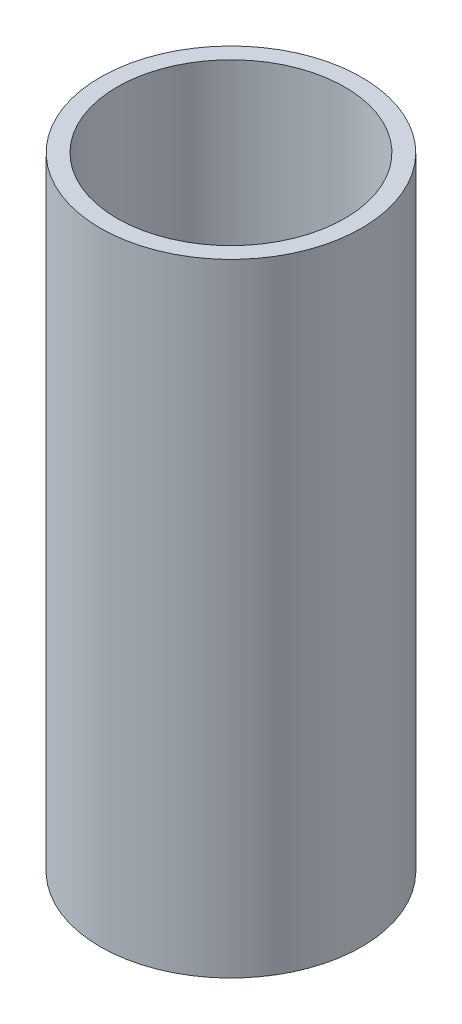
from build123d import *

# Parameters (mm, degrees)
SKETCH1_R           = 10.5
SKETCH1_R_2         = 9.146610041
BOSS_EXTRUDE1_DEPTH = 50


with BuildPart() as part:
    # Sketch1 → Boss-Extrude1 (new body)
    with BuildSketch(Plane(origin=(0, 0, 0), x_dir=(1, 0, 0), z_dir=(0, 1, 0))):
        Circle(SKETCH1_R)
        Circle(SKETCH1_R_2, mode=Mode.SUBTRACT)
    extrude(amount=BOSS_EXTRUDE1_DEPTH)


solid = part.part
